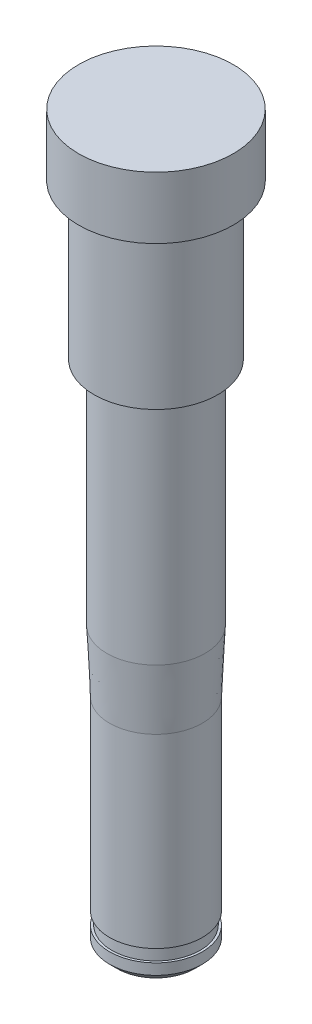
from build123d import *

# Parameters (mm, degrees)
CHAMFER5_SIZE = 0.5
SKETCH3_W     = 0.15
SKETCH3_H     = 0.8


with BuildPart() as part:
    # Sketch1 → Revolve1 (revolve)
    with BuildSketch(Plane.XY):
        Polygon((0, -16.9), (-3.175, -16.9), (-3.175, 16), (-4, 16), (-4, 26), (-5, 26), (-5, 30), (0, 30), (0, 18.825290935), align=None)
    revolve(axis=Axis((0, 55, 0), (0, -1, 0)))

    # Sketch2 → Cut-Revolve1 (revolve, cut)
    with BuildSketch(Plane.XY):
        Polygon((-3, -2.9), (-3.175, 1.1), (-3.175, -3.698889695), (-3.175, -16.9), (-3, -16.9), align=None)
    revolve(axis=Axis((0, 55, 0), (0, -1, 0)), mode=Mode.SUBTRACT)

    # Chamfer5
    chamfer5_edges = [part.edges().sort_by_distance(p)[0] for p in [
        (3, -16.9, 0),
    ]]
    chamfer(chamfer5_edges, length=CHAMFER5_SIZE)

    # Sketch3 → Cut-Revolve2 (revolve, cut)
    with BuildSketch(Plane(origin=(0, 0, 0), x_dir=(0, 0, -1), z_dir=(1, 0, 0))):
        with Locations((2.925, -15.3)):
            Rectangle(SKETCH3_W, SKETCH3_H)
    revolve(axis=Axis((0, 55, 0), (0, -1, 0)), mode=Mode.SUBTRACT)


solid = part.part
